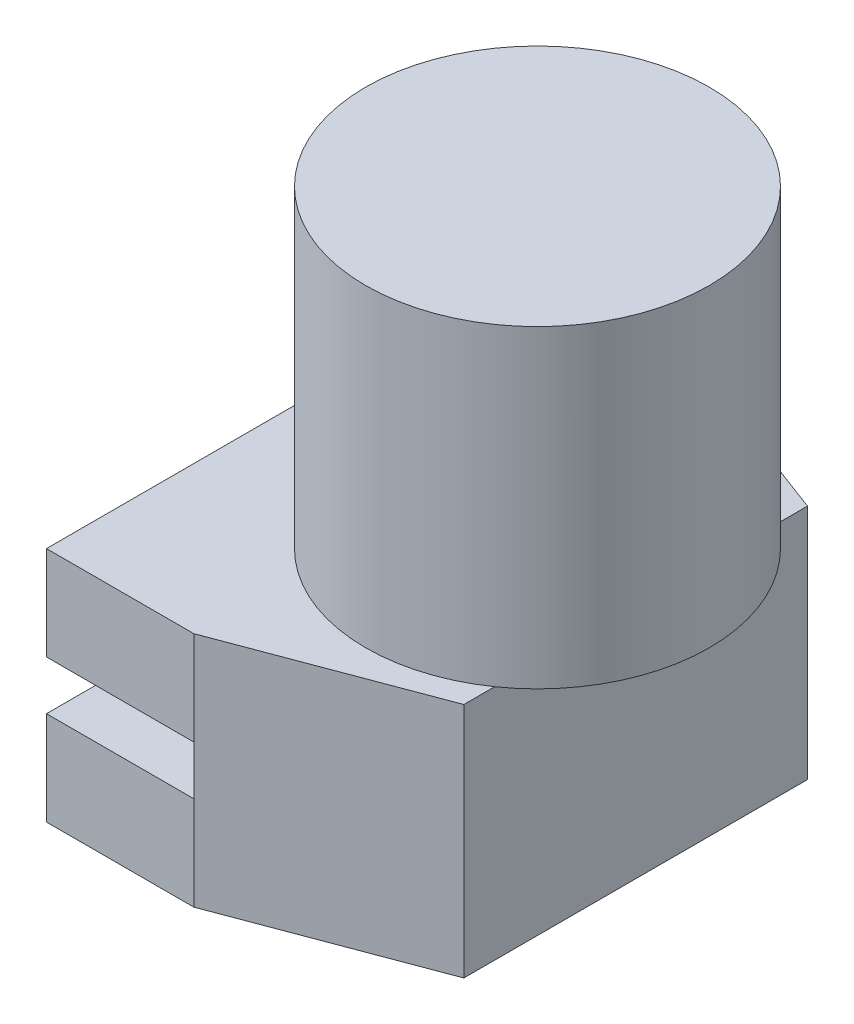
from build123d import *

# Parameters (mm, degrees)
BASE_APPROXIMATE_DEPTH       = 30.6324
BEAM_CHANNEL_CROSS_SECTION_W = 38.1
BEAM_CHANNEL_CROSS_SECTION_H = 12.7
BEAM_CHANNEL_DEPTH           = 64.5
BEAM_CHANNEL_DEPTH_BACK      = 64.5
HOLE_CROSS_SECTION_R         = 19.05
HOLE_DEPTH                   = 25.4
ROUND_PART_CROSS_SECTION_R   = 44.45
ROUND_PART_DEPTH             = 81.153


with BuildPart() as part:
    # Base → Base Approximate (new body, symmetric)
    with BuildSketch(Plane(origin=(0, 0, 0), x_dir=(1, 0, 0), z_dir=(0, 1, 0))):
        Polygon((0, -63.5), (0, 63.5), (38.1, 63.5), (88.9, 44.45), (88.9, -44.45), (38.1, -63.5), align=None)
    extrude(amount=BASE_APPROXIMATE_DEPTH, both=True)

    # Beam Channel Cross Section → Beam Channel (cut, two sides)
    with BuildSketch(Plane.XY) as beam_channel_sk:
        with Locations((19.05, 0)):
            Rectangle(BEAM_CHANNEL_CROSS_SECTION_W, BEAM_CHANNEL_CROSS_SECTION_H)
    extrude(amount=BEAM_CHANNEL_DEPTH, mode=Mode.SUBTRACT)
    extrude(beam_channel_sk.sketch, amount=-BEAM_CHANNEL_DEPTH_BACK, mode=Mode.SUBTRACT)

    # Hole Cross Section → Hole (cut)
    with BuildSketch(Plane(origin=(0, 30.6324, 0), x_dir=(1, 0, 0), z_dir=(0, 1, 0))):
        with Locations((63.5, 0)):
            Circle(HOLE_CROSS_SECTION_R)
    extrude(amount=-HOLE_DEPTH, mode=Mode.SUBTRACT)

    # Round Part Cross Section → Round Part (add)
    with BuildSketch(Plane(origin=(0, 30.6324, 0), x_dir=(1, 0, 0), z_dir=(0, 1, 0))):
        with Locations((63.5, 0)):
            Circle(ROUND_PART_CROSS_SECTION_R)
    extrude(amount=ROUND_PART_DEPTH)


solid = part.part
